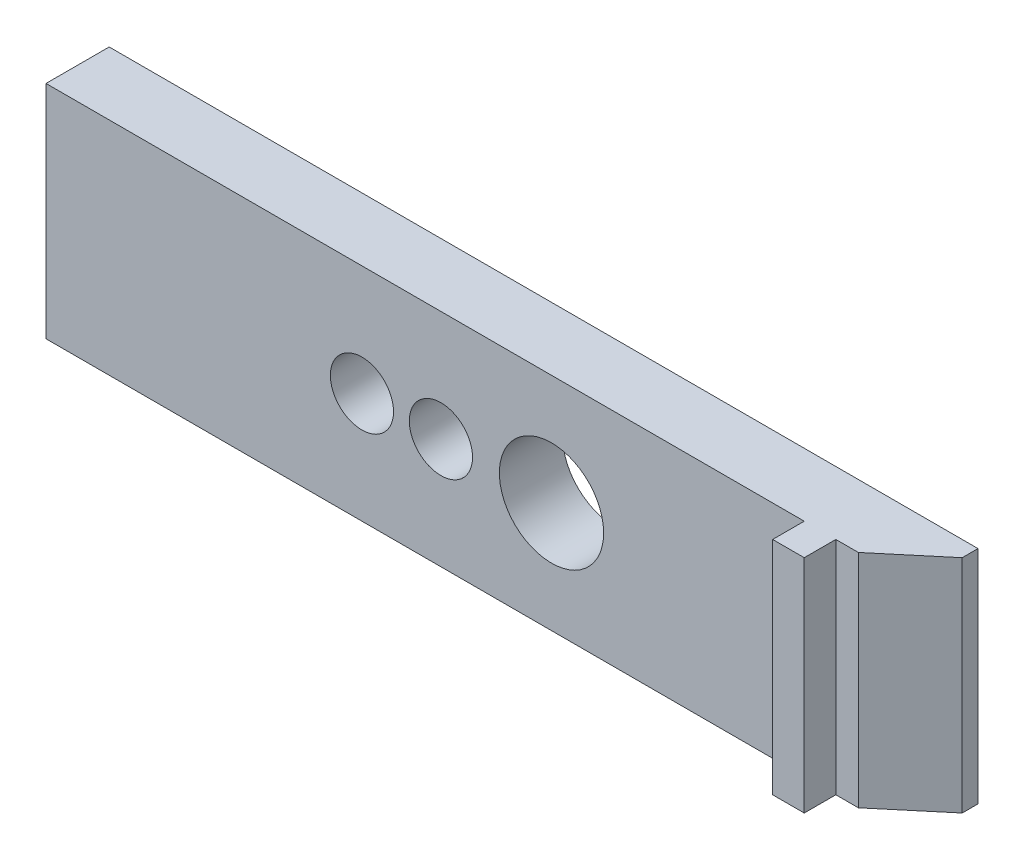
from build123d import *

# Parameters (mm, degrees)
ESBO_O1_W                = 27.5
ESBO_O1_H                = 7
ESBO_O1_R                = 1.65
ESBO_O1_R_2              = 1
RESSALTO_EXTRUS_O1_DEPTH = 2
CHANFRO1_SIZE            = 1.5
CHANFRO1_SIZE2           = 1.787630389
ESBO_O2_W                = 1
ESBO_O2_H                = 7
RESSALTO_EXTRUS_O2_DEPTH = 1


with BuildPart() as part:
    # Esboço1 → Ressalto-extrusão1 (new body)
    with BuildSketch(Plane.XY):
        Rectangle(ESBO_O1_W, ESBO_O1_H)
        with Locations((2.25, 0)):
            Circle(ESBO_O1_R, mode=Mode.SUBTRACT)
        with Locations((-1.25, 0)):
            Circle(ESBO_O1_R_2, mode=Mode.SUBTRACT)
        with Locations((-3.75, 0)):
            Circle(ESBO_O1_R_2, mode=Mode.SUBTRACT)
    extrude(amount=RESSALTO_EXTRUS_O1_DEPTH)

    # Chanfro1
    chanfro1_edges = [part.edges().sort_by_distance(p)[0] for p in [
        (13.75, 0, 2),
    ]]
    chanfro1_side = [part.faces().sort_by_distance(p)[0] for p in [
        (13.75, 0, 1),
    ]]
    chamfer(chanfro1_edges, length=CHANFRO1_SIZE, length2=CHANFRO1_SIZE2, reference=chanfro1_side[0])

    # Esboço2 → Ressalto-extrusão2 (add)
    with BuildSketch(Plane.XY.offset(2)):
        with Locations((10.75, 0)):
            Rectangle(ESBO_O2_W, ESBO_O2_H)
    extrude(amount=RESSALTO_EXTRUS_O2_DEPTH)


solid = part.part
